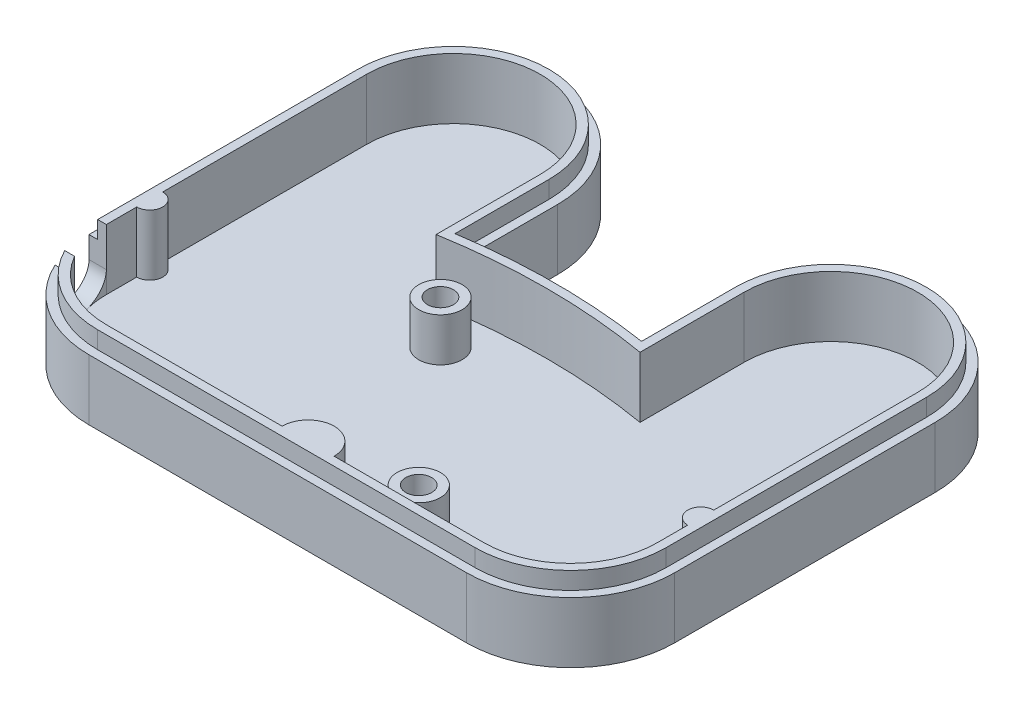
from build123d import *

# Parameters (mm, degrees)
EXTRUDE_1_DEPTH     = 2
EXTRUDE_3_DEPTH     = 9
EXTRUDE_5_DEPTH     = 7
SKETCH_3_R          = 2.5
SKETCH_3_R_2        = 1.5
EXTRUDE_8_DEPTH     = 5
EXTRUDE_9_DEPTH     = 7
CUT_EXTRUDE_2_DEPTH = 5


with BuildPart() as part:
    # 草图1 → 凸台-拉伸1 (new body)
    with BuildSketch(Plane(origin=(0, 0, 0), x_dir=(1, 0, 0), z_dir=(0, 1, 0))):
        with BuildLine():
            Line((0, 28), (0, 40))
            ThreePointArc((0, 40), (10, 50), (20, 40))
            Line((20, 40), (20, 28))
            ThreePointArc((20, 28), (31.75, 29), (43.5, 28))
            Line((43.5, 28), (43.5, 40))
            ThreePointArc((43.5, 40), (53.5, 50), (63.5, 40))
            Line((63.5, 40), (63.5, 28))
            Line((63.5, 28), (63.5, 10))
            ThreePointArc((63.5, 10), (60.571067812, 2.928932188), (53.5, 0))
            Line((53.5, 0), (10, 0))
            ThreePointArc((10, 0), (2.928932188, 2.928932188), (0, 10))
            Line((0, 10), (0, 28))
        make_face()
    extrude(amount=EXTRUDE_1_DEPTH)

    # 草图1<4> → 凸台-拉伸3 (add)
    with BuildSketch(Plane(origin=(0, 0, 0), x_dir=(1, 0, 0), z_dir=(0, 1, 0))):
        with BuildLine():
            Line((42.5, 40), (42.5, 29.175957135))
            ThreePointArc((42.5, 29.175957135), (31.75, 30), (21, 29.175957135))
            Line((21, 29.175957135), (21, 40))
            ThreePointArc((21, 40), (10, 51), (-1, 40))
            Line((-1, 40), (-1, 28))
            Line((-1, 28), (-1, 10))
            ThreePointArc((-1, 10), (2.221825407, 2.221825407), (10, -1))
            Line((10, -1), (53.5, -1))
            ThreePointArc((53.5, -1), (61.278174593, 2.221825407), (64.5, 10))
            Line((64.5, 10), (64.5, 28))
            Line((64.5, 28), (64.5, 40))
            ThreePointArc((64.5, 40), (53.5, 51), (42.5, 40))
        make_face()
        with BuildLine():
            Line((0, 28), (0, 40))
            ThreePointArc((0, 40), (10, 50), (20, 40))
            Line((20, 40), (20, 28))
            ThreePointArc((20, 28), (31.75, 29), (43.5, 28))
            Line((43.5, 28), (43.5, 40))
            ThreePointArc((43.5, 40), (53.5, 50), (63.5, 40))
            Line((63.5, 40), (63.5, 28))
            Line((63.5, 28), (63.5, 10))
            ThreePointArc((63.5, 10), (60.571067812, 2.928932188), (53.5, 0))
            Line((53.5, 0), (10, 0))
            ThreePointArc((10, 0), (2.928932188, 2.928932188), (0, 10))
            Line((0, 10), (0, 28))
        make_face(mode=Mode.SUBTRACT)
    extrude(amount=EXTRUDE_3_DEPTH)

    # 草图1<6> → 凸台-拉伸5 (add)
    with BuildSketch(Plane(origin=(0, 0, 0), x_dir=(1, 0, 0), z_dir=(0, 1, 0))):
        with BuildLine():
            Line((10, -2), (53.5, -2))
            ThreePointArc((53.5, -2), (61.985281374, 1.514718626), (65.5, 10))
            Line((65.5, 10), (65.5, 28))
            Line((65.5, 28), (65.5, 40))
            ThreePointArc((65.5, 40), (53.5, 52), (41.5, 40))
            Line((41.5, 40), (41.5, 30.332402365))
            ThreePointArc((41.5, 30.332402365), (31.75, 31), (22, 30.332402365))
            Line((22, 30.332402365), (22, 40))
            ThreePointArc((22, 40), (10, 52), (-2, 40))
            Line((-2, 40), (-2, 28))
            Line((-2, 28), (-2, 10))
            ThreePointArc((-2, 10), (1.514718626, 1.514718626), (10, -2))
        make_face()
        with BuildLine():
            Line((42.5, 40), (42.5, 29.175957135))
            ThreePointArc((42.5, 29.175957135), (31.75, 30), (21, 29.175957135))
            Line((21, 29.175957135), (21, 40))
            ThreePointArc((21, 40), (10, 51), (-1, 40))
            Line((-1, 40), (-1, 28))
            Line((-1, 28), (-1, 10))
            ThreePointArc((-1, 10), (2.221825407, 2.221825407), (10, -1))
            Line((10, -1), (53.5, -1))
            ThreePointArc((53.5, -1), (61.278174593, 2.221825407), (64.5, 10))
            Line((64.5, 10), (64.5, 28))
            Line((64.5, 28), (64.5, 40))
            ThreePointArc((64.5, 40), (53.5, 51), (42.5, 40))
        make_face(mode=Mode.SUBTRACT)
    extrude(amount=EXTRUDE_5_DEPTH)

    # 草图3 → 凸台-拉伸8 (add)
    # profile 1 of 2: a face of its own
    with BuildSketch(Plane(origin=(0, 2, 0), x_dir=(1, 0, 0), z_dir=(0, 1, 0))):
        with Locations((24.5, 24)):
            Circle(SKETCH_3_R)
        with Locations((24.5, 24)):
            Circle(SKETCH_3_R_2, mode=Mode.SUBTRACT)
    # profile 2 of 2: a face of its own
    with BuildSketch(Plane(origin=(0, 2, 0), x_dir=(1, 0, 0), z_dir=(0, 1, 0))):
        with Locations((42, 4)):
            Circle(SKETCH_3_R)
        with Locations((42, 4)):
            Circle(SKETCH_3_R_2, mode=Mode.SUBTRACT)
    extrude(amount=EXTRUDE_8_DEPTH)

    # 草图3<7> → 凸台-拉伸9 (add)
    with BuildSketch(Plane(origin=(0, 2, 0), x_dir=(1, 0, 0), z_dir=(0, 1, 0))):
        with BuildLine():
            Line((63.5, 13.5), (63.5, 16.5))
            ThreePointArc((63.5, 16.5), (62, 15), (63.5, 13.5))
        make_face()
        with BuildLine():
            Line((0, 16.5), (0, 13.5))
            ThreePointArc((0, 13.5), (1.5, 15), (0, 16.5))
        make_face()
        with BuildLine():
            ThreePointArc((36.25, 0), (33.25, 3), (30.25, 0))
            Line((30.25, 0), (36.25, 0))
        make_face()
    extrude(amount=EXTRUDE_9_DEPTH)

    # 草图4 → 切除-拉伸2 (cut)
    with BuildSketch(Plane.ZY.offset(2)):
        with BuildLine():
            Line((-10, 4.5), (-10, 9))
            Line((-10, 9), (-5, 9))
            Line((-5, 9), (-5, 4.5))
            ThreePointArc((-5, 4.5), (-7.5, 2), (-10, 4.5))
        make_face()
    extrude(amount=-CUT_EXTRUDE_2_DEPTH, mode=Mode.SUBTRACT)


solid = part.part
